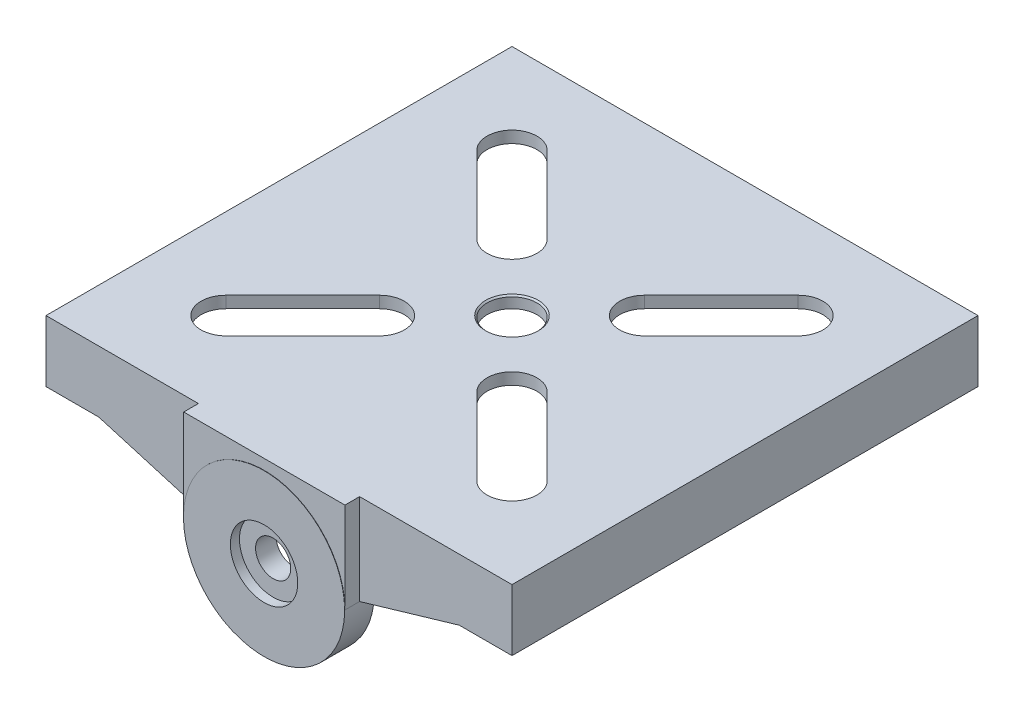
from build123d import *

# Parameters (mm, degrees)
SKETCH2_W                = 159
SKETCH2_H                = 159
BOSS_EXTRUDE1_DEPTH      = 21
SHELL1_T                 = -2
BOSS_EXTRUDE2_DEPTH      = 5
BOSS_EXTRUDE2_DEPTH_BACK = 5
BOSS_EXTRUDE3_DEPTH      = 2
SKETCH6_R                = 11.5
CUT_EXTRUDE1_DEPTH       = 3
SKETCH7_R                = 6
CUT_EXTRUDE2_DEPTH       = 7
SKETCH8_R                = 8.5
CUT_EXTRUDE3_DEPTH       = 59.5
BOSS_EXTRUDE4_DEPTH      = 2
BOSS_EXTRUDE5_START      = 27.5
BOSS_EXTRUDE5_DEPTH      = 2
BOSS_EXTRUDE6_START      = -27.5
BOSS_EXTRUDE6_DEPTH      = 2
CHAMFER3_SIZE            = 0.5
SKETCH14_R               = 27.5
SKETCH14_R_2             = 11.5
BOSS_EXTRUDE7_DEPTH      = 0.1


with BuildPart() as part:
    # Sketch2 → Boss-Extrude1 (new body)
    with BuildSketch(Plane(origin=(0, 0, 0), x_dir=(1, 0, 0), z_dir=(0, 1, 0))):
        with Locations((79.5, 79.5)):
            Rectangle(SKETCH2_W, SKETCH2_H)
    extrude(amount=BOSS_EXTRUDE1_DEPTH)

    # Shell1
    shell1_openings = [part.faces().sort_by_distance(p)[0] for p in [
        (79.5, 0, -79.5),
    ]]
    offset(amount=SHELL1_T, openings=shell1_openings, kind=Kind.INTERSECTION)

    # Sketch4 → Boss-Extrude2 (add, two sides)
    with BuildSketch(Plane.XY) as boss_extrude2_sk:
        with BuildLine():
            Line((107, 21), (52, 21))
            Line((52, 21), (52, -10))
            ThreePointArc((52, -10), (79.5, -37.5), (107, -10))
            Line((107, -10), (107, 21))
        make_face()
    extrude(amount=BOSS_EXTRUDE2_DEPTH)
    extrude(boss_extrude2_sk.sketch, amount=-BOSS_EXTRUDE2_DEPTH_BACK)

    # Sketch5 → Boss-Extrude3 (add)
    with BuildSketch(Plane.XY):
        Polygon((52, -10), (52, 0), (18, 0), align=None)
        Polygon((107, 0), (107, -10), (141, 0), align=None)
    extrude(amount=-BOSS_EXTRUDE3_DEPTH)

    # Sketch6 → Cut-Extrude1 (cut)
    with BuildSketch(Plane.XY.offset(5)):
        with Locations((79.5, -10)):
            Circle(SKETCH6_R)
    extrude(amount=-CUT_EXTRUDE1_DEPTH, mode=Mode.SUBTRACT)

    # Sketch7 → Cut-Extrude2 (cut)
    with BuildSketch(Plane.XY.offset(2)):
        with Locations((79.5, -10)):
            Circle(SKETCH7_R)
    extrude(amount=-CUT_EXTRUDE2_DEPTH, mode=Mode.SUBTRACT)

    # Sketch8 → Cut-Extrude3 (cut, through all)
    with BuildSketch(Plane(origin=(0, 21, 0), x_dir=(1, 0, 0), z_dir=(0, 1, 0))):
        with Locations((79.5, 79.5)):
            Circle(SKETCH8_R)
        with BuildLine():
            Line((24.699224458, 122.279960262), (50.862175362, 96.117009358))
            ThreePointArc((50.862175362, 96.117009358), (62.882990642, 96.117009358), (62.882990642, 108.137824638))
            Line((62.882990642, 108.137824638), (36.720039738, 134.300775542))
            ThreePointArc((36.720039738, 134.300775542), (24.699224458, 134.300775542), (24.699224458, 122.279960262))
        make_face()
        with BuildLine():
            Line((122.279960262, 134.300775542), (96.117009358, 108.137824638))
            ThreePointArc((96.117009358, 108.137824638), (96.117009358, 96.117009358), (108.137824638, 96.117009358))
            Line((108.137824638, 96.117009358), (134.300775542, 122.279960262))
            ThreePointArc((134.300775542, 122.279960262), (134.300775542, 134.300775542), (122.279960262, 134.300775542))
        make_face()
        with BuildLine():
            Line((134.300775542, 36.720039738), (108.137824638, 62.882990642))
            ThreePointArc((108.137824638, 62.882990642), (96.117009358, 62.882990642), (96.117009358, 50.862175362))
            Line((96.117009358, 50.862175362), (122.279960262, 24.699224458))
            ThreePointArc((122.279960262, 24.699224458), (134.300775542, 24.699224458), (134.300775542, 36.720039738))
        make_face()
        with BuildLine():
            Line((50.862175362, 62.882990642), (24.699224458, 36.720039738))
            ThreePointArc((24.699224458, 36.720039738), (24.699224458, 24.699224458), (36.720039738, 24.699224458))
            Line((36.720039738, 24.699224458), (62.882990642, 50.862175362))
            ThreePointArc((62.882990642, 50.862175362), (62.882990642, 62.882990642), (50.862175362, 62.882990642))
        make_face()
    extrude(amount=-CUT_EXTRUDE3_DEPTH, mode=Mode.SUBTRACT)

    # Sketch9 → Boss-Extrude4 (add)
    with BuildSketch(Plane.XZ.offset(-19)):
        with BuildLine():
            ThreePointArc((49.094408409, -64.650757595), (55.099393063, -67.728724003), (61.77164987, -66.721397338))
            Line((61.77164987, -66.721397338), (59.874934843, -64.824682311))
            ThreePointArc((59.874934843, -64.824682311), (55.082431735, -65.181936674), (50.862175362, -62.882990642))
            Line((50.862175362, -62.882990642), (24.699224458, -36.720039738))
            ThreePointArc((24.699224458, -36.720039738), (24.699224458, -24.699224458), (36.720039738, -24.699224458))
            Line((36.720039738, -24.699224458), (62.882990642, -50.862175362))
            ThreePointArc((62.882990642, -50.862175362), (65.181936674, -55.082431735), (64.824682311, -59.874934843))
            Line((64.824682311, -59.874934843), (66.721397338, -61.77164987))
            ThreePointArc((66.721397338, -61.77164987), (67.728724003, -55.099393063), (64.650757595, -49.094408409))
            Line((64.650757595, -49.094408409), (38.487806691, -22.931457505))
            ThreePointArc((38.487806691, -22.931457505), (22.931457505, -22.931457505), (22.931457505, -38.487806691))
            Line((22.931457505, -38.487806691), (49.094408409, -64.650757595))
        make_face()
        with BuildLine():
            Line((94.175317689, -99.125065157), (92.278602662, -97.22835013))
            ThreePointArc((92.278602662, -97.22835013), (91.271275997, -103.900606937), (94.349242405, -109.905591591))
            Line((94.349242405, -109.905591591), (120.512193309, -136.068542495))
            ThreePointArc((120.512193309, -136.068542495), (136.068542495, -136.068542495), (136.068542495, -120.512193309))
            Line((136.068542495, -120.512193309), (109.905591591, -94.349242405))
            ThreePointArc((109.905591591, -94.349242405), (103.900606937, -91.271275997), (97.22835013, -92.278602662))
            Line((97.22835013, -92.278602662), (99.125065157, -94.175317689))
            ThreePointArc((99.125065157, -94.175317689), (103.917568265, -93.818063326), (108.137824638, -96.117009358))
            Line((108.137824638, -96.117009358), (134.300775542, -122.279960262))
            ThreePointArc((134.300775542, -122.279960262), (134.300775542, -134.300775542), (122.279960262, -134.300775542))
            Line((122.279960262, -134.300775542), (96.117009358, -108.137824638))
            ThreePointArc((96.117009358, -108.137824638), (93.818063326, -103.917568265), (94.175317689, -99.125065157))
        make_face()
        with BuildLine():
            Line((59.874934843, -64.824682311), (61.77164987, -66.721397338))
            ThreePointArc((61.77164987, -66.721397338), (64.650757595, -64.650757595), (66.721397338, -61.77164987))
            Line((66.721397338, -61.77164987), (64.824682311, -59.874934843))
            ThreePointArc((64.824682311, -59.874934843), (62.882990642, -62.882990642), (59.874934843, -64.824682311))
        make_face()
        with BuildLine():
            ThreePointArc((97.22835013, -92.278602662), (94.349242405, -94.349242405), (92.278602662, -97.22835013))
            Line((92.278602662, -97.22835013), (94.175317689, -99.125065157))
            ThreePointArc((94.175317689, -99.125065157), (96.117009358, -96.117009358), (99.125065157, -94.175317689))
            Line((99.125065157, -94.175317689), (97.22835013, -92.278602662))
        make_face()
        with BuildLine():
            ThreePointArc((71.547900691, -82.502351841), (71, -79.5), (71.547900691, -76.497648159))
            Line((71.547900691, -76.497648159), (67.805581809, -72.755329277))
            ThreePointArc((67.805581809, -72.755329277), (66, -79.5), (67.805581809, -86.244670723))
            Line((67.805581809, -86.244670723), (71.547900691, -82.502351841))
        make_face()
        with BuildLine():
            Line((67.805581809, -72.755329277), (71.547900691, -76.497648159))
            ThreePointArc((71.547900691, -76.497648159), (73.48959236, -73.48959236), (76.497648159, -71.547900691))
            Line((76.497648159, -71.547900691), (72.755329277, -67.805581809))
            ThreePointArc((72.755329277, -67.805581809), (69.954058454, -69.954058454), (67.805581809, -72.755329277))
        make_face()
        with BuildLine():
            Line((72.755329277, -67.805581809), (76.497648159, -71.547900691))
            ThreePointArc((76.497648159, -71.547900691), (79.5, -71), (82.502351841, -71.547900691))
            Line((82.502351841, -71.547900691), (86.244670723, -67.805581809))
            ThreePointArc((86.244670723, -67.805581809), (79.5, -66), (72.755329277, -67.805581809))
        make_face()
        with BuildLine():
            ThreePointArc((82.502351841, -71.547900691), (85.51040764, -73.48959236), (87.452099309, -76.497648159))
            Line((87.452099309, -76.497648159), (91.194418191, -72.755329277))
            ThreePointArc((91.194418191, -72.755329277), (89.045941546, -69.954058454), (86.244670723, -67.805581809))
            Line((86.244670723, -67.805581809), (82.502351841, -71.547900691))
        make_face()
        with BuildLine():
            ThreePointArc((88, -79.5), (87.861903017, -81.025967869), (87.452099309, -82.502351841))
            Line((87.452099309, -82.502351841), (91.194418191, -86.244670723))
            ThreePointArc((91.194418191, -86.244670723), (92.540794561, -82.991085391), (93, -79.5))
            ThreePointArc((93, -79.5), (92.540794561, -76.008914609), (91.194418191, -72.755329277))
            Line((91.194418191, -72.755329277), (87.452099309, -76.497648159))
            ThreePointArc((87.452099309, -76.497648159), (87.861903017, -77.974032131), (88, -79.5))
        make_face()
        with BuildLine():
            ThreePointArc((87.452099309, -82.502351841), (85.51040764, -85.51040764), (82.502351841, -87.452099309))
            Line((82.502351841, -87.452099309), (86.244670723, -91.194418191))
            ThreePointArc((86.244670723, -91.194418191), (89.045941546, -89.045941546), (91.194418191, -86.244670723))
            Line((91.194418191, -86.244670723), (87.452099309, -82.502351841))
        make_face()
        with BuildLine():
            ThreePointArc((76.497648159, -87.452099309), (73.48959236, -85.51040764), (71.547900691, -82.502351841))
            Line((71.547900691, -82.502351841), (67.805581809, -86.244670723))
            ThreePointArc((67.805581809, -86.244670723), (69.954058454, -89.045941546), (72.755329277, -91.194418191))
            Line((72.755329277, -91.194418191), (76.497648159, -87.452099309))
        make_face()
        with BuildLine():
            ThreePointArc((82.502351841, -87.452099309), (79.5, -88), (76.497648159, -87.452099309))
            Line((76.497648159, -87.452099309), (72.755329277, -91.194418191))
            ThreePointArc((72.755329277, -91.194418191), (79.5, -93), (86.244670723, -91.194418191))
            Line((86.244670723, -91.194418191), (82.502351841, -87.452099309))
        make_face()
        with BuildLine():
            ThreePointArc((72.755329277, -91.194418191), (69.954058454, -89.045941546), (67.805581809, -86.244670723))
            Line((67.805581809, -86.244670723), (61.77164987, -92.278602662))
            ThreePointArc((61.77164987, -92.278602662), (64.650757595, -94.349242405), (66.721397338, -97.22835013))
            Line((66.721397338, -97.22835013), (72.755329277, -91.194418191))
        make_face()
        with BuildLine():
            ThreePointArc((91.194418191, -86.244670723), (89.045941546, -89.045941546), (86.244670723, -91.194418191))
            Line((86.244670723, -91.194418191), (92.278602662, -97.22835013))
            ThreePointArc((92.278602662, -97.22835013), (94.349242405, -94.349242405), (97.22835013, -92.278602662))
            Line((97.22835013, -92.278602662), (91.194418191, -86.244670723))
        make_face()
        with BuildLine():
            ThreePointArc((86.244670723, -67.805581809), (89.045941546, -69.954058454), (91.194418191, -72.755329277))
            Line((91.194418191, -72.755329277), (97.22835013, -66.721397338))
            ThreePointArc((97.22835013, -66.721397338), (94.349242405, -64.650757595), (92.278602662, -61.77164987))
            Line((92.278602662, -61.77164987), (86.244670723, -67.805581809))
        make_face()
        with BuildLine():
            Line((61.77164987, -66.721397338), (67.805581809, -72.755329277))
            ThreePointArc((67.805581809, -72.755329277), (69.954058454, -69.954058454), (72.755329277, -67.805581809))
            Line((72.755329277, -67.805581809), (66.721397338, -61.77164987))
            ThreePointArc((66.721397338, -61.77164987), (64.650757595, -64.650757595), (61.77164987, -66.721397338))
        make_face()
        with BuildLine():
            Line((99.125065157, -64.824682311), (97.22835013, -66.721397338))
            ThreePointArc((97.22835013, -66.721397338), (103.900606937, -67.728724003), (109.905591591, -64.650757595))
            Line((109.905591591, -64.650757595), (136.068542495, -38.487806691))
            ThreePointArc((136.068542495, -38.487806691), (136.068542495, -22.931457505), (120.512193309, -22.931457505))
            Line((120.512193309, -22.931457505), (94.349242405, -49.094408409))
            ThreePointArc((94.349242405, -49.094408409), (91.271275997, -55.099393063), (92.278602662, -61.77164987))
            Line((92.278602662, -61.77164987), (94.175317689, -59.874934843))
            ThreePointArc((94.175317689, -59.874934843), (93.818063326, -55.082431735), (96.117009358, -50.862175362))
            Line((96.117009358, -50.862175362), (122.279960262, -24.699224458))
            ThreePointArc((122.279960262, -24.699224458), (134.300775542, -24.699224458), (134.300775542, -36.720039738))
            Line((134.300775542, -36.720039738), (108.137824638, -62.882990642))
            ThreePointArc((108.137824638, -62.882990642), (103.917568265, -65.181936674), (99.125065157, -64.824682311))
        make_face()
        with BuildLine():
            Line((59.874934843, -94.175317689), (61.77164987, -92.278602662))
            ThreePointArc((61.77164987, -92.278602662), (55.099393063, -91.271275997), (49.094408409, -94.349242405))
            Line((49.094408409, -94.349242405), (22.931457505, -120.512193309))
            ThreePointArc((22.931457505, -120.512193309), (22.931457505, -136.068542495), (38.487806691, -136.068542495))
            Line((38.487806691, -136.068542495), (64.650757595, -109.905591591))
            ThreePointArc((64.650757595, -109.905591591), (67.728724003, -103.900606937), (66.721397338, -97.22835013))
            Line((66.721397338, -97.22835013), (64.824682311, -99.125065157))
            ThreePointArc((64.824682311, -99.125065157), (65.181936674, -103.917568265), (62.882990642, -108.137824638))
            Line((62.882990642, -108.137824638), (36.720039738, -134.300775542))
            ThreePointArc((36.720039738, -134.300775542), (24.699224458, -134.300775542), (24.699224458, -122.279960262))
            Line((24.699224458, -122.279960262), (50.862175362, -96.117009358))
            ThreePointArc((50.862175362, -96.117009358), (55.082431735, -93.818063326), (59.874934843, -94.175317689))
        make_face()
        with BuildLine():
            ThreePointArc((66.721397338, -97.22835013), (64.650757595, -94.349242405), (61.77164987, -92.278602662))
            Line((61.77164987, -92.278602662), (59.874934843, -94.175317689))
            ThreePointArc((59.874934843, -94.175317689), (62.882990642, -96.117009358), (64.824682311, -99.125065157))
            Line((64.824682311, -99.125065157), (66.721397338, -97.22835013))
        make_face()
        with BuildLine():
            ThreePointArc((92.278602662, -61.77164987), (94.349242405, -64.650757595), (97.22835013, -66.721397338))
            Line((97.22835013, -66.721397338), (99.125065157, -64.824682311))
            ThreePointArc((99.125065157, -64.824682311), (96.117009358, -62.882990642), (94.175317689, -59.874934843))
            Line((94.175317689, -59.874934843), (92.278602662, -61.77164987))
        make_face()
    extrude(amount=BOSS_EXTRUDE4_DEPTH)

    # Sketch13 → Boss-Extrude5 (add)
    with BuildSketch(Plane(origin=(79.5, 0, 0), x_dir=(0, 0, -1), z_dir=(1, 0, 0)).offset(BOSS_EXTRUDE5_START)):
        Polygon((5, 19), (5, 3), (21, 19), align=None)
    extrude(amount=-BOSS_EXTRUDE5_DEPTH)

    # Sketch13_2 → Boss-Extrude6 (add)
    with BuildSketch(Plane(origin=(79.5, 0, 0), x_dir=(0, 0, -1), z_dir=(1, 0, 0)).offset(BOSS_EXTRUDE6_START)):
        Polygon((5, 19), (5, 3), (21, 19), align=None)
    extrude(amount=BOSS_EXTRUDE6_DEPTH)

    # Chamfer3
    chamfer3_edges = [part.edges().sort_by_distance(p)[0] for p in [
        (71, 21, -79.5),
    ]]
    chamfer(chamfer3_edges, length=CHAMFER3_SIZE)

    # Sketch14 → Boss-Extrude7 (add)
    with BuildSketch(Plane.XY.offset(5)):
        with Locations((79.5, -10)):
            Circle(SKETCH14_R)
        with Locations((79.5, -10)):
            Circle(SKETCH14_R_2, mode=Mode.SUBTRACT)
    extrude(amount=BOSS_EXTRUDE7_DEPTH)


solid = part.part
